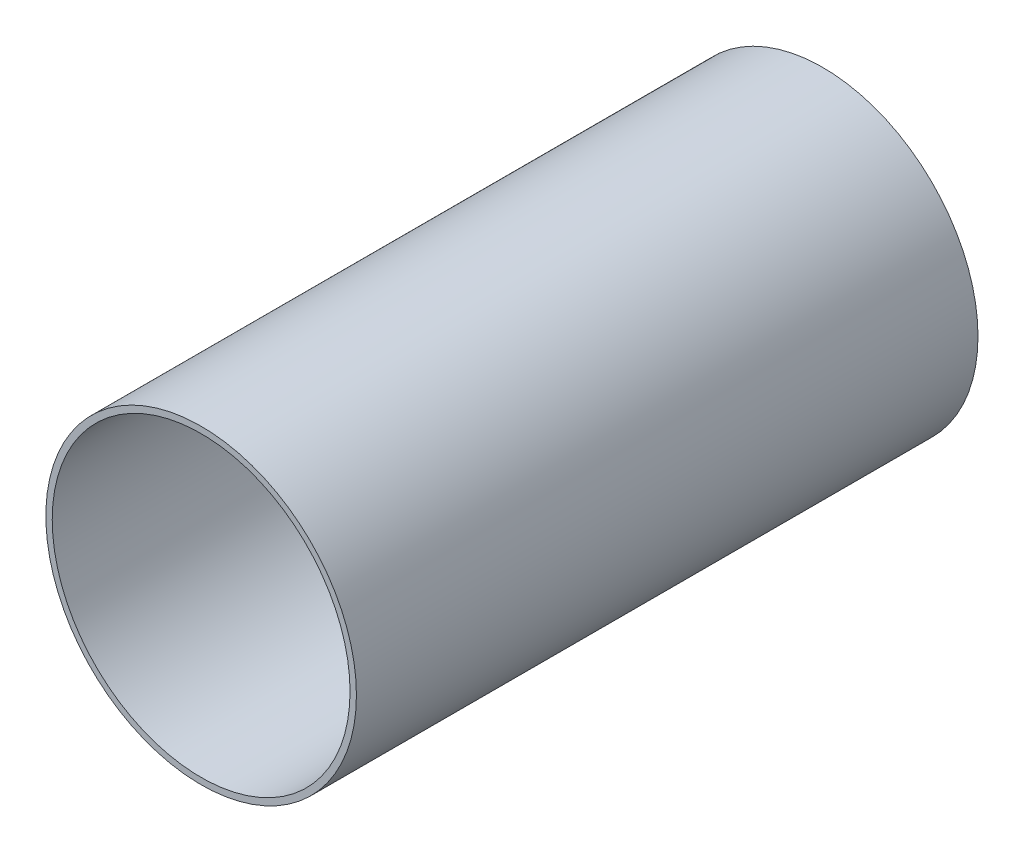
from build123d import *

# Parameters (mm, degrees)
SKETCH1_R           = 38.0746
SKETCH1_R_2         = 36.5125
BOSS_EXTRUDE1_DEPTH = 76.2


with BuildPart() as part:
    # Sketch1 → Boss-Extrude1 (new body, symmetric)
    with BuildSketch(Plane.XY):
        Circle(SKETCH1_R)
        Circle(SKETCH1_R_2, mode=Mode.SUBTRACT)
    extrude(amount=BOSS_EXTRUDE1_DEPTH, both=True)


solid = part.part
